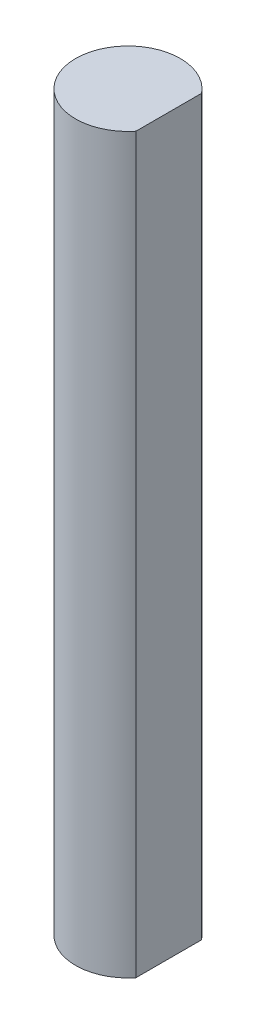
from build123d import *

# Parameters (mm, degrees)
BOSS_EXTRUDE1_DEPTH = 63.5
CUT_EXTRUDE1_DEPTH  = 19.05


with BuildPart() as part:
    # Sketch1 → Boss-Extrude1 (new body)
    with BuildSketch(Plane(origin=(0, 0, 0), x_dir=(1, 0, 0), z_dir=(0, 1, 0))):
        with BuildLine():
            Line((2.47212698, 1.992288431), (2.47212698, -1.992288431))
            ThreePointArc((2.47212698, -1.992288431), (-3.175, 0), (2.47212698, 1.992288431))
        make_face()
    extrude(amount=BOSS_EXTRUDE1_DEPTH)

    # Sketch3 → Cut-Extrude1 (cut)
    with BuildSketch(Plane(origin=(0, 63.5, 0), x_dir=(1, 0, 0), z_dir=(0, 1, 0))):
        with BuildLine():
            Line((2.47212698, -1.992288431), (2.47212698, 1.992288431))
            ThreePointArc((2.47212698, 1.992288431), (-3.175, 0), (2.47212698, -1.992288431))
        make_face()
    extrude(amount=-CUT_EXTRUDE1_DEPTH, mode=Mode.SUBTRACT)


solid = part.part
